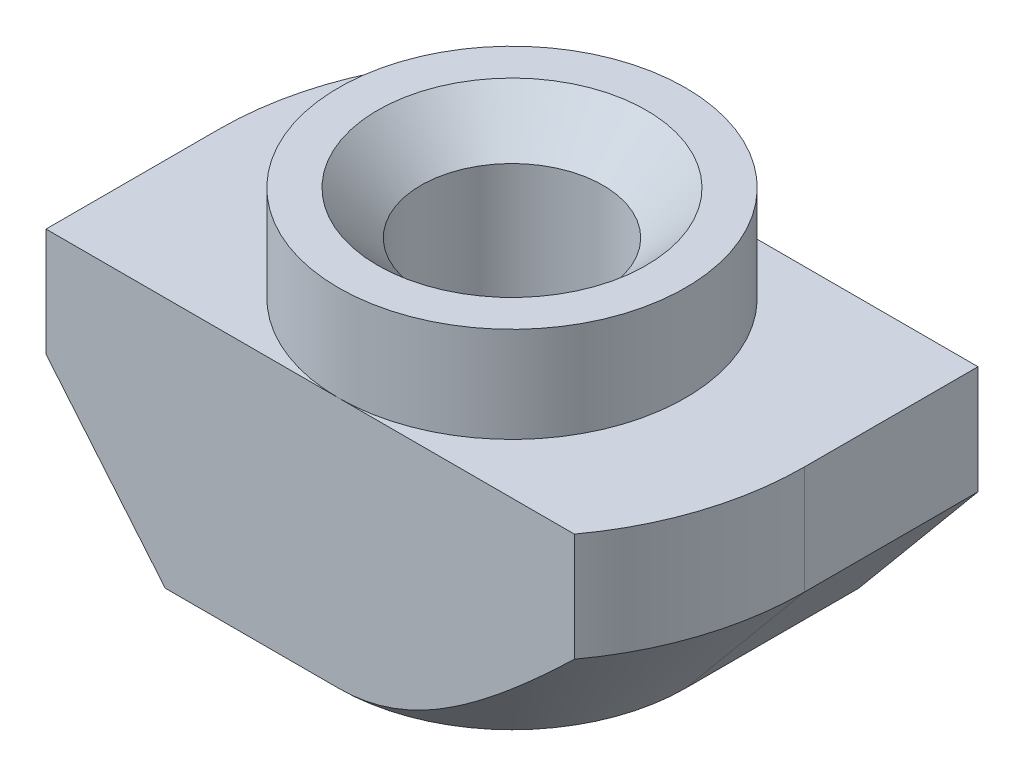
from build123d import *

# Parameters (mm, degrees)
EXTRUDE_1_DEPTH     = 4
SKETCH_4_OUTSIDE_W  = 19.022
SKETCH_4_OUTSIDE_H  = 13.522
SKETCH_4_OUTSIDE_R  = 4
CUT_EXTRUDE_1_DEPTH = 2.2
CUT_EXTRUDE_2_DEPTH = 6.8


with BuildPart() as part:
    # Эскиз1 → Бобышка-Вытянуть1 (new body, symmetric)
    with BuildSketch(Plane.XY):
        Polygon((4, 0), (-4, 0), (-4, -2.2), (-6.75, -2.2), (-6.75, -8), (6.75, -8), (6.75, -2.2), (4, -2.2), align=None)
    extrude(amount=EXTRUDE_1_DEPTH, both=True)

    # Эскиз3 → Отверстие обработанное метчиком M51 (revolve, cut)
    with BuildSketch(Plane(origin=(0, 0, 0), x_dir=(0, 0, 1), z_dir=(1, 0, 0))):
        Polygon((0, 0), (0, 8), (3.1, 8), (2.1, 7), (2.1, 1), (3.1, 0), align=None)
    revolve(axis=Axis((0, 6.35, 0), (0, -1, 0)), mode=Mode.SUBTRACT)

    # Эскиз4 outside → Вырез-Вытянуть1 (cut)
    with BuildSketch(Plane(origin=(0, 0, 0), x_dir=(1, 0, 0), z_dir=(0, 1, 0))):
        Rectangle(SKETCH_4_OUTSIDE_W, SKETCH_4_OUTSIDE_H)
        with Locations(Location((0, 0, 0), (0, 0, 270))):  # turned: the seam where the file's is
            Circle(SKETCH_4_OUTSIDE_R, mode=Mode.SUBTRACT)
    extrude(amount=-CUT_EXTRUDE_1_DEPTH, mode=Mode.SUBTRACT)

    # Эскиз5 → Вырез-Вытянуть2 (cut, through all)
    with BuildSketch(Plane(origin=(0, -2.2, 0), x_dir=(1, 0, 0), z_dir=(0, 1, 0))):
        with BuildLine():
            Line((-6.75, 0), (-6.75, 4))
            Line((-6.75, 4), (-5.437140793, 4))
            ThreePointArc((-5.437140793, 4), (-6.413392252, 2.104970267), (-6.75, 0))
        make_face()
        with BuildLine():
            Line((6.75, 0), (6.75, -4))
            Line((6.75, -4), (5.437140793, -4))
            ThreePointArc((5.437140793, -4), (6.413392252, -2.104970267), (6.75, 0))
        make_face()
    extrude(amount=-CUT_EXTRUDE_2_DEPTH, mode=Mode.SUBTRACT)

    # Вырез-По траектории1: sweep along a path in Эскиз7
    with BuildLine(Plane.XZ.offset(8)) as sweep_1_path:
        Line((0, 6.75), (-6.75, 6.75))
        Line((-6.75, 6.75), (-6.75, 0))
        ThreePointArc((-6.75, 0), (-4.772970773, -4.772970773), (0, -6.75))
        Line((0, -6.75), (6.75, -6.75))
        Line((6.75, -6.75), (6.75, 0))
        ThreePointArc((6.75, 0), (4.772970773, 4.772970773), (0, 6.75))
    # Эскиз6 → Вырез-По траектории1 (sweep, cut)
    with BuildSketch(Plane.XY.offset(4)):
        Polygon((-6.75, -4.7), (-6.75, -8), (-4, -8), align=None)
    sweep(path=sweep_1_path.line, transition=Transition.RIGHT, mode=Mode.SUBTRACT)


solid = part.part
